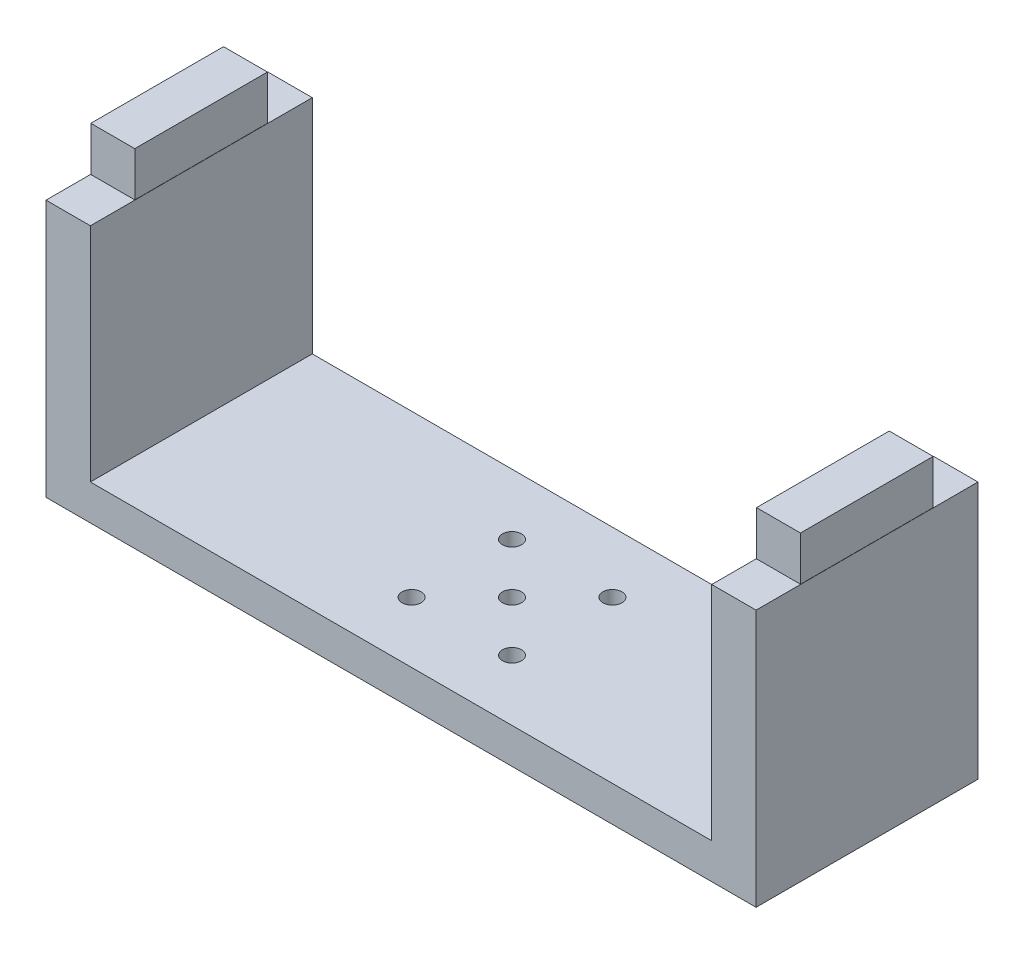
from build123d import *

# Parameters (mm, degrees)
SKETCH1_W           = 160
SKETCH1_H           = 50
BOSS_EXTRUDE1_DEPTH = 8
SKETCH2_W           = 10
SKETCH2_H           = 50
BOSS_EXTRUDE2_DEPTH = 50
SKETCH3_W           = 9.9
SKETCH3_H           = 29.9
BOSS_EXTRUDE3_DEPTH = 10
CUT_EXTRUDE1_REACH  = 70
SKETCH4_R           = 2.15


with BuildPart() as part:
    # Sketch1 → Boss-Extrude1 (new body)
    with BuildSketch(Plane(origin=(0, 0, 0), x_dir=(1, 0, 0), z_dir=(0, 1, 0))):
        Rectangle(SKETCH1_W, SKETCH1_H)
    extrude(amount=BOSS_EXTRUDE1_DEPTH)

    # Sketch2 → Boss-Extrude2 (add)
    with BuildSketch(Plane(origin=(0, 8, 0), x_dir=(1, 0, 0), z_dir=(0, 1, 0))):
        with Locations((-75, 0)):
            Rectangle(SKETCH2_W, SKETCH2_H)
        with Locations((75, 0)):
            Rectangle(SKETCH2_W, SKETCH2_H)
    extrude(amount=BOSS_EXTRUDE2_DEPTH)

    # Sketch3 → Boss-Extrude3 (add)
    with BuildSketch(Plane(origin=(0, 58, 0), x_dir=(1, 0, 0), z_dir=(0, 1, 0))):
        with Locations((-75, 0)):
            Rectangle(SKETCH3_W, SKETCH3_H)
        with Locations((75, 0)):
            Rectangle(SKETCH3_W, SKETCH3_H)
    extrude(amount=BOSS_EXTRUDE3_DEPTH)

    # Sketch4 → Cut-Extrude1 (cut, up to next)
    with BuildSketch(Plane.XZ, mode=Mode.PRIVATE) as cut_extrude1_sk1:
        Circle(SKETCH4_R)
    cut_extrude1_tool1 = extrude(cut_extrude1_sk1.sketch, amount=-CUT_EXTRUDE1_REACH, mode=Mode.PRIVATE) & part.part
    add(cut_extrude1_tool1.solids().sort_by_distance((0, 0, 0))[0], mode=Mode.SUBTRACT)
    # Sketch4 → Cut-Extrude1 (cut, up to next)
    with BuildSketch(Plane.XZ, mode=Mode.PRIVATE) as cut_extrude1_sk2:
        with Locations((-11.313708499, 11.313708499)):
            Circle(SKETCH4_R)
    cut_extrude1_tool2 = extrude(cut_extrude1_sk2.sketch, amount=-CUT_EXTRUDE1_REACH, mode=Mode.PRIVATE) & part.part
    add(cut_extrude1_tool2.solids().sort_by_distance((-11.313708, 0, 11.313708))[0], mode=Mode.SUBTRACT)
    # Sketch4 → Cut-Extrude1 (cut, up to next)
    with BuildSketch(Plane.XZ, mode=Mode.PRIVATE) as cut_extrude1_sk3:
        with Locations((11.313708499, 11.313708499)):
            Circle(SKETCH4_R)
    cut_extrude1_tool3 = extrude(cut_extrude1_sk3.sketch, amount=-CUT_EXTRUDE1_REACH, mode=Mode.PRIVATE) & part.part
    add(cut_extrude1_tool3.solids().sort_by_distance((11.313708, 0, 11.313708))[0], mode=Mode.SUBTRACT)
    # Sketch4 → Cut-Extrude1 (cut, up to next)
    with BuildSketch(Plane.XZ, mode=Mode.PRIVATE) as cut_extrude1_sk4:
        with Locations((11.313708499, -11.313708499)):
            Circle(SKETCH4_R)
    cut_extrude1_tool4 = extrude(cut_extrude1_sk4.sketch, amount=-CUT_EXTRUDE1_REACH, mode=Mode.PRIVATE) & part.part
    add(cut_extrude1_tool4.solids().sort_by_distance((11.313708, 0, -11.313708))[0], mode=Mode.SUBTRACT)
    # Sketch4 → Cut-Extrude1 (cut, up to next)
    with BuildSketch(Plane.XZ, mode=Mode.PRIVATE) as cut_extrude1_sk5:
        with Locations((-11.313708499, -11.313708499)):
            Circle(SKETCH4_R)
    cut_extrude1_tool5 = extrude(cut_extrude1_sk5.sketch, amount=-CUT_EXTRUDE1_REACH, mode=Mode.PRIVATE) & part.part
    add(cut_extrude1_tool5.solids().sort_by_distance((-11.313708, 0, -11.313708))[0], mode=Mode.SUBTRACT)


solid = part.part
